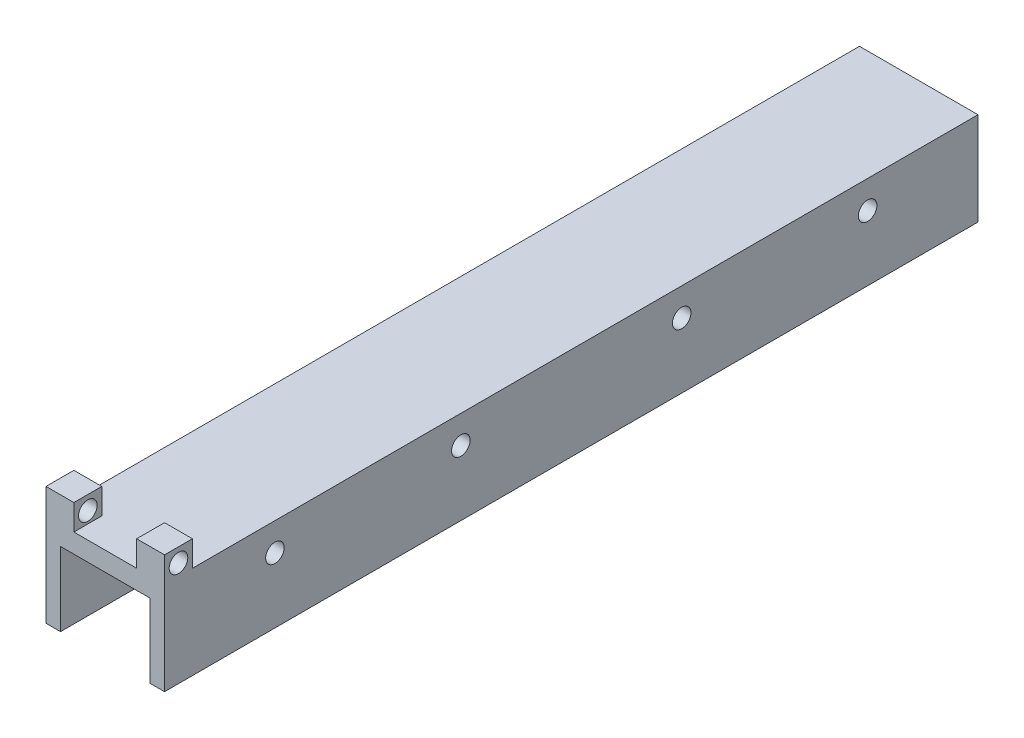
from build123d import *

# Parameters (mm, degrees)
BOSS_EXTRUDE2_DEPTH     = 177.8
SKETCH19_R              = 2.032
CUT_EXTRUDE3_DEPTH      = 26.908
SKETCH21_W              = 6.096
SKETCH21_H              = 6.096
BOSS_EXTRUDE4_DEPTH     = 5.588
SKETCH22_R              = 2.032
CUT_EXTRUDE4_DEPTH      = 20.812
CUT_EXTRUDE4_DEPTH_BACK = 7.096


with BuildPart() as part:
    # Sketch2 → Boss-Extrude2 (new body)
    with BuildSketch(Plane.XY):
        Polygon((0, 0), (0, 20.32), (25.908, 20.32), (25.908, 0), (22.733, 0), (22.733, 16.129), (3.175, 16.129), (3.175, 0), align=None)
    extrude(amount=-BOSS_EXTRUDE2_DEPTH)

    # Sketch19 → Cut-Extrude3 (cut, through all)
    with BuildSketch(Plane(origin=(0, 0, 0), x_dir=(0, 0, -1), z_dir=(1, 0, 0))):
        with Locations((24.13, 14.224)):
            Circle(SKETCH19_R)
        with Locations((64.77, 14.224)):
            Circle(SKETCH19_R)
        with Locations((113.03, 14.224)):
            Circle(SKETCH19_R)
        with Locations((153.67, 14.224)):
            Circle(SKETCH19_R)
    extrude(amount=CUT_EXTRUDE3_DEPTH, mode=Mode.SUBTRACT)

    # Sketch21 → Boss-Extrude4 (add)
    with BuildSketch(Plane(origin=(0, 20.32, 0), x_dir=(1, 0, 0), z_dir=(0, 1, 0))):
        with Locations((3.048, 3.048)):
            Rectangle(SKETCH21_W, SKETCH21_H)
        with Locations((22.86, 3.048)):
            Rectangle(SKETCH21_W, SKETCH21_H)
    extrude(amount=BOSS_EXTRUDE4_DEPTH)

    # Sketch22 → Cut-Extrude4 (cut, two sides)
    with BuildSketch(Plane.ZY.offset(-19.812)) as cut_extrude4_sk:
        with Locations((-3.048, 22.86)):
            Circle(SKETCH22_R)
    extrude(amount=CUT_EXTRUDE4_DEPTH, mode=Mode.SUBTRACT)
    extrude(cut_extrude4_sk.sketch, amount=-CUT_EXTRUDE4_DEPTH_BACK, mode=Mode.SUBTRACT)


solid = part.part
